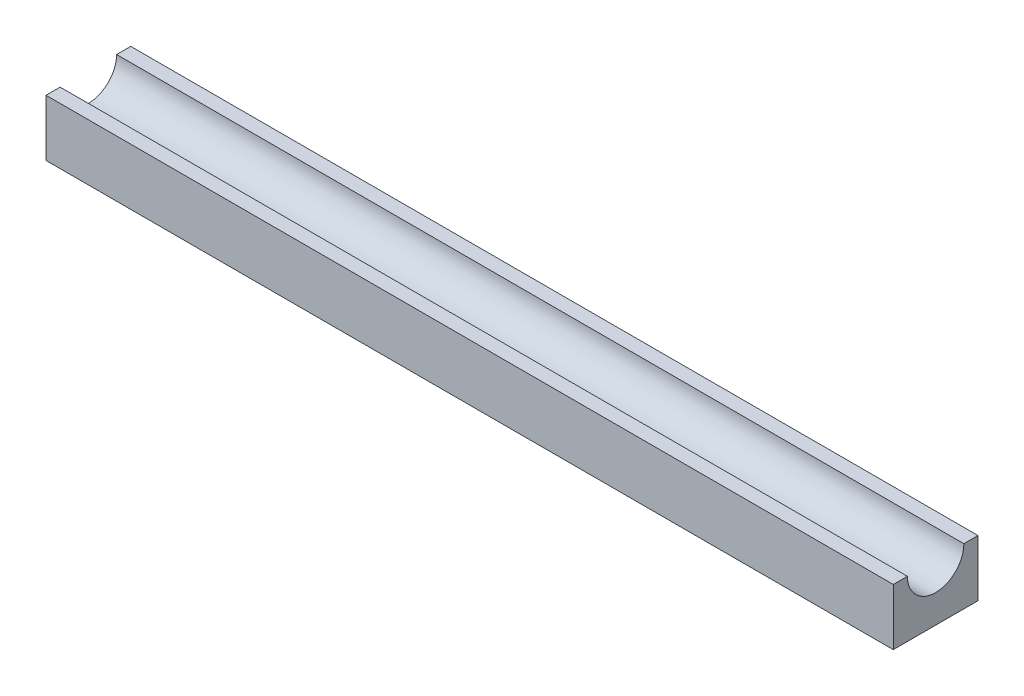
from build123d import *

# Parameters (mm, degrees)
BOSS_EXTRUDE1_DEPTH     = 150
BOSS_EXTRUDE6_DEPTH     = 1.5
SKETCH7_R               = 0.5
CUT_EXTRUDE1_DEPTH      = 8.5
CUT_EXTRUDE1_DEPTH_BACK = 8.5
SKETCH9_R               = 0.5
CUT_EXTRUDE2_DEPTH      = 10


with BuildPart() as part:
    # Sketch1 → Boss-Extrude1 (new body)
    with BuildSketch(Plane(origin=(0, 0, 0), x_dir=(0, 0, -1), z_dir=(1, 0, 0))):
        with BuildLine():
            Line((7.5, 5), (5, 5))
            ThreePointArc((5, 5), (0, 0), (-5, 5))
            Line((-5, 5), (-7.5, 5))
            Line((-7.5, 5), (-7.5, -5))
            Line((-7.5, -5), (7.5, -5))
            Line((7.5, -5), (7.5, 5))
        make_face()
    extrude(amount=BOSS_EXTRUDE1_DEPTH)

    # Sketch6 → Boss-Extrude6 (add, symmetric)
    with BuildSketch(Plane.XY):
        with BuildLine():
            ThreePointArc((77.5, -8), (75, -5.5), (72.5, -8))
            Line((72.5, -8), (77.5, -8))
        make_face()
        with BuildLine():
            Line((77.5, -8), (72.5, -8))
            ThreePointArc((72.5, -8), (75, -10.5), (77.5, -8))
        make_face()
        with BuildLine():
            Line((77.5, -5), (72.5, -5))
            Line((72.5, -5), (72.5, -8))
            ThreePointArc((72.5, -8), (75, -5.5), (77.5, -8))
            Line((77.5, -8), (77.5, -5))
        make_face()
    boss_extrude6 = extrude(amount=BOSS_EXTRUDE6_DEPTH, both=True)

    # Mirror1: Boss-Extrude6 across plane
    add(boss_extrude6.mirror(Plane.ZY.offset(-45)))

    # Sketch7 → Cut-Extrude1 (cut, two sides)
    with BuildSketch(Plane.XY) as cut_extrude1_sk:
        with Locations((75, -8)):
            Circle(SKETCH7_R)
    extrude(amount=CUT_EXTRUDE1_DEPTH, mode=Mode.SUBTRACT)
    extrude(cut_extrude1_sk.sketch, amount=-CUT_EXTRUDE1_DEPTH_BACK, mode=Mode.SUBTRACT)

    # Sketch9 → Cut-Extrude2 (cut)
    with BuildSketch(Plane.XY.offset(1.5)):
        with Locations((15, -8)):
            Circle(SKETCH9_R)
    extrude(amount=-CUT_EXTRUDE2_DEPTH, mode=Mode.SUBTRACT)


solid = part.part
